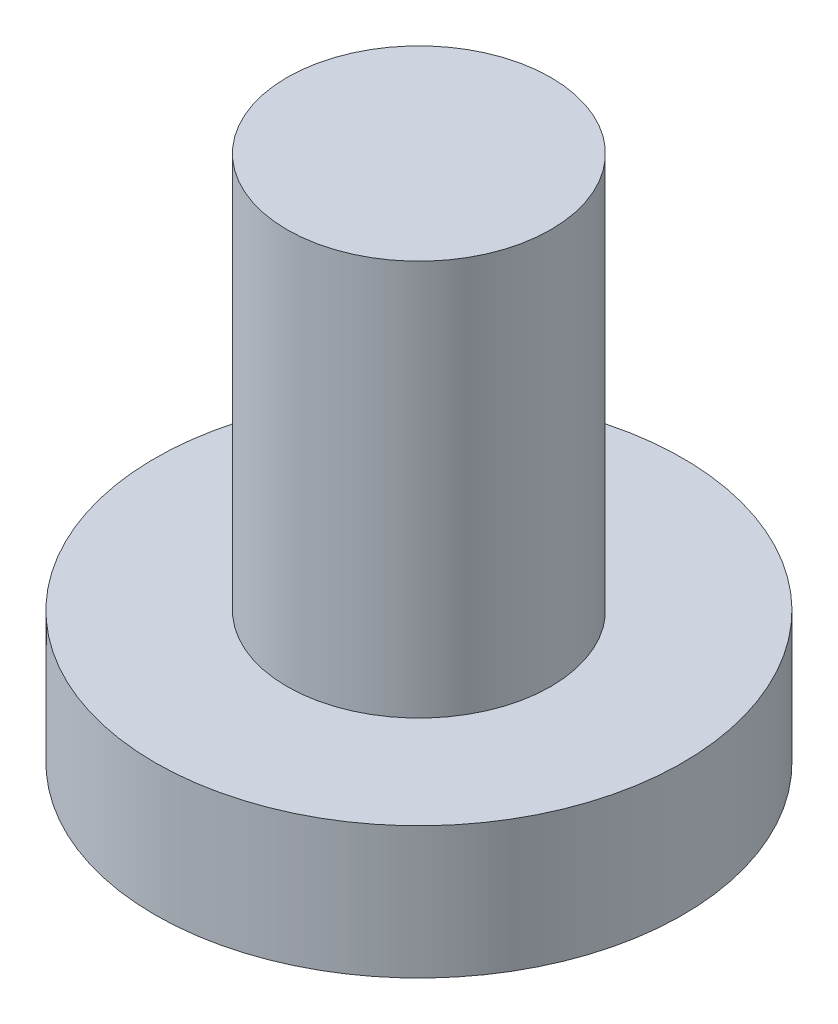
from build123d import *

# Parameters (mm, degrees)
SKETCH2_R           = 2
BOSS_EXTRUDE1_DEPTH = 1
SKETCH3_R           = 1
BOSS_EXTRUDE3_DEPTH = 3


with BuildPart() as part:
    # Sketch2 → Boss-Extrude1 (new body)
    with BuildSketch(Plane(origin=(0, 0, 0), x_dir=(1, 0, 0), z_dir=(0, 1, 0))):
        Circle(SKETCH2_R)
    extrude(amount=BOSS_EXTRUDE1_DEPTH)

    # Sketch3 → Boss-Extrude3 (add)
    with BuildSketch(Plane(origin=(0, 1, 0), x_dir=(1, 0, 0), z_dir=(0, 1, 0))):
        Circle(SKETCH3_R)
    extrude(amount=BOSS_EXTRUDE3_DEPTH)


solid = part.part
